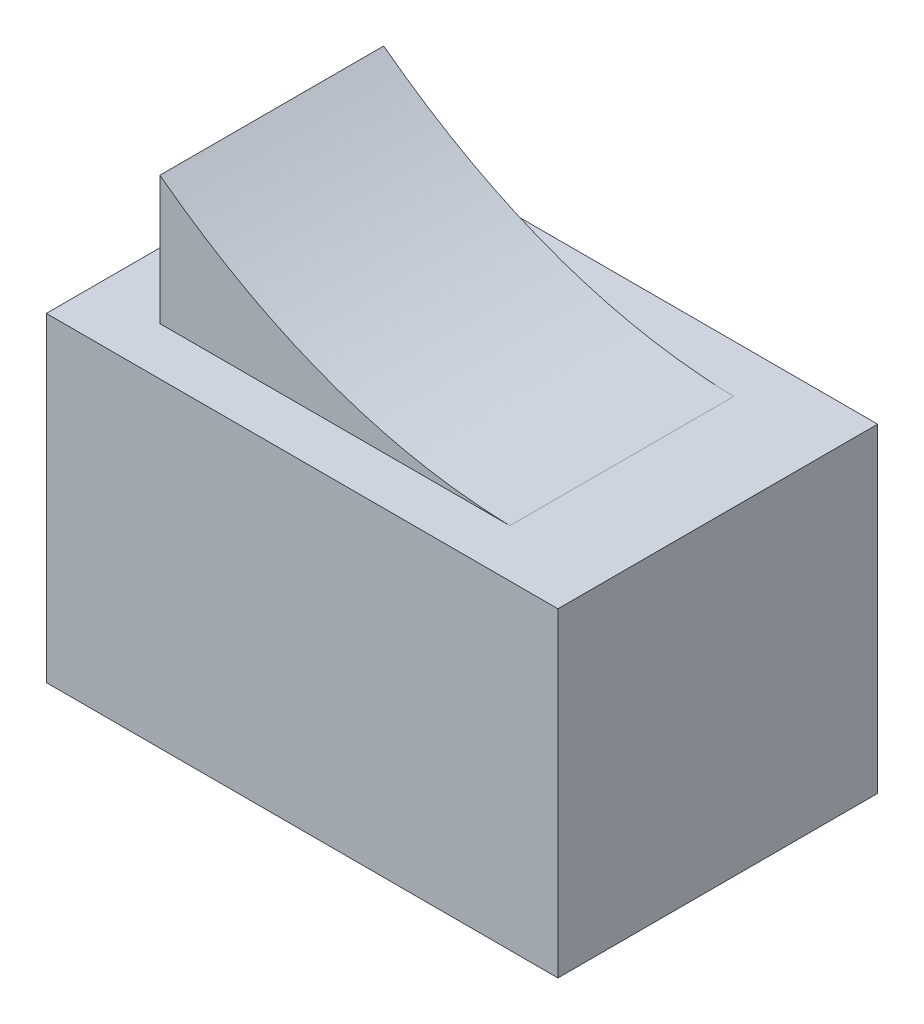
from build123d import *

# Parameters (mm, degrees)
SKETCH1_W           = 20.32
SKETCH1_H           = 12.7
BOSS_EXTRUDE1_DEPTH = 12.7
BOSS_EXTRUDE2_DEPTH = 4.445


with BuildPart() as part:
    # Sketch1 → Boss-Extrude1 (new body)
    with BuildSketch(Plane(origin=(0, 0, 0), x_dir=(1, 0, 0), z_dir=(0, 1, 0))):
        Rectangle(SKETCH1_W, SKETCH1_H)
    extrude(amount=BOSS_EXTRUDE1_DEPTH)

    # Sketch2 → Boss-Extrude2 (add, symmetric)
    with BuildSketch(Plane.XY):
        with BuildLine():
            Line((-7.555612539, 17.803216518), (-7.555612539, 12.7))
            Line((-7.555612539, 12.7), (6.347718594, 12.7))
            add(Edge.make_bspline(
                [(-7.555612539, 17.803216518), (-1.024019713, 12.888036176), (6.347718594, 12.7)],
                knots=[0, 0, 0, 0.926306801, 0.926306801, 0.926306801], degree=2))
        make_face()
    extrude(amount=BOSS_EXTRUDE2_DEPTH, both=True)


solid = part.part
